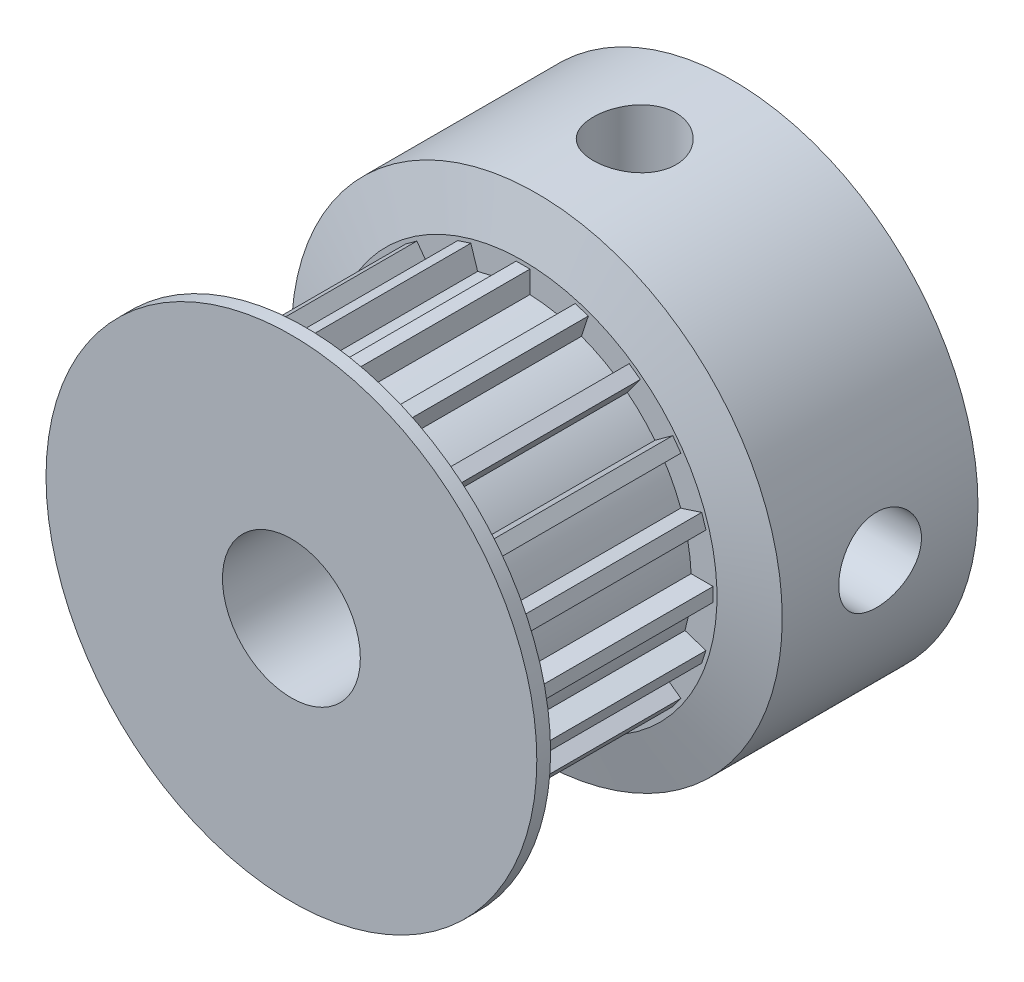
from build123d import *

# Parameters (mm, degrees)
CHAMFER1_SIZE       = 0.5
CHAMFER1_SIZE2      = 1.866025404
CHAMFER2_SIZE       = 0.5
CHAMFER2_SIZE2      = 1.866025404
BOSS_EXTRUDE1_DEPTH = 7.4
SKETCH6_R           = 1.5
CUT_EXTRUDE1_DEPTH  = 10
CIRPATTERN1_COUNT   = 2
CIRPATTERN1_ANGLE   = 270


with BuildPart() as part:
    # Sketch2 → Revolve1 (revolve)
    with BuildSketch(Plane(origin=(0, 0, 0), x_dir=(0, 0, -1), z_dir=(1, 0, 0))):
        Polygon((-16, 2.5), (0, 2.5), (0, 8.9), (-7.6, 8.9), (-7.6, 6.1), (-15, 6.1), (-15, 8.9), (-16, 8.9), align=None)
    revolve(axis=Axis((0, 0, 79.609460318), (0, 0, -1)))

    # Chamfer1
    chamfer1_edges = [part.edges().sort_by_distance(p)[0] for p in [
        (0, -8.9, 15),
    ]]
    chamfer1_side = [part.faces().sort_by_distance(p)[0] for p in [
        (0, -8.9, 15.5),
    ]]
    chamfer(chamfer1_edges, length=CHAMFER1_SIZE, length2=CHAMFER1_SIZE2, reference=chamfer1_side[0])

    # Chamfer2
    chamfer2_edges = [part.edges().sort_by_distance(p)[0] for p in [
        (0, -8.9, 7.6),
    ]]
    chamfer2_side = [part.faces().sort_by_distance(p)[0] for p in [
        (0, -8.9, 3.8),
    ]]
    chamfer(chamfer2_edges, length=CHAMFER2_SIZE, length2=CHAMFER2_SIZE2, reference=chamfer2_side[0])

    # Sketch4 → Boss-Extrude1 (add)
    with BuildSketch(Plane.XY.offset(7.6)):
        with BuildLine():
            Line((1.645655792, 5.873824735), (1.892869388, 6.634669948))
            Line((1.892869388, 6.634669948), (2.368397646, 6.48016145))
            Line((2.368397646, 6.48016145), (2.121184051, 5.719316237))
            ThreePointArc((2.121184051, 5.719316237), (1.885003666, 5.801444749), (1.645655792, 5.873824735))
        make_face()
        with BuildLine():
            Line((-0.25, 6.094874896), (-0.25, 6.894874896))
            Line((-0.25, 6.894874896), (0.25, 6.894874896))
            Line((0.25, 6.894874896), (0.25, 6.094874896))
            ThreePointArc((0.25, 6.094874896), (0, 6.1), (-0.25, 6.094874896))
        make_face()
        with BuildLine():
            Line((3.38022333, 5.077803683), (3.850451532, 5.725017278))
            Line((3.850451532, 5.725017278), (4.254960029, 5.431124652))
            Line((4.254960029, 5.431124652), (3.784731827, 4.783911057))
            ThreePointArc((3.784731827, 4.783911057), (3.585490039, 4.935003666), (3.38022333, 5.077803683))
        make_face()
        with BuildLine():
            Line((4.783911057, 3.784731827), (5.431124652, 4.254960029))
            Line((5.431124652, 4.254960029), (5.725017278, 3.850451532))
            Line((5.725017278, 3.850451532), (5.077803683, 3.38022333))
            ThreePointArc((5.077803683, 3.38022333), (4.935003666, 3.585490039), (4.783911057, 3.784731827))
        make_face()
        with BuildLine():
            Line((5.719316237, 2.121184051), (6.48016145, 2.368397646))
            Line((6.48016145, 2.368397646), (6.634669948, 1.892869388))
            Line((6.634669948, 1.892869388), (5.873824735, 1.645655792))
            ThreePointArc((5.873824735, 1.645655792), (5.801444749, 1.885003666), (5.719316237, 2.121184051))
        make_face()
        with BuildLine():
            Line((6.094874896, 0.25), (6.894874896, 0.25))
            Line((6.894874896, 0.25), (6.894874896, -0.25))
            Line((6.894874896, -0.25), (6.094874896, -0.25))
            ThreePointArc((6.094874896, -0.25), (6.1, 0), (6.094874896, 0.25))
        make_face()
        with BuildLine():
            Line((5.873824735, -1.645655792), (6.634669948, -1.892869388))
            Line((6.634669948, -1.892869388), (6.48016145, -2.368397646))
            Line((6.48016145, -2.368397646), (5.719316237, -2.121184051))
            ThreePointArc((5.719316237, -2.121184051), (5.801444749, -1.885003666), (5.873824735, -1.645655792))
        make_face()
        with BuildLine():
            Line((5.077803683, -3.38022333), (5.725017278, -3.850451532))
            Line((5.725017278, -3.850451532), (5.431124652, -4.254960029))
            Line((5.431124652, -4.254960029), (4.783911057, -3.784731827))
            ThreePointArc((4.783911057, -3.784731827), (4.935003666, -3.585490039), (5.077803683, -3.38022333))
        make_face()
        with BuildLine():
            Line((3.784731827, -4.783911057), (4.254960029, -5.431124652))
            Line((4.254960029, -5.431124652), (3.850451532, -5.725017278))
            Line((3.850451532, -5.725017278), (3.38022333, -5.077803683))
            ThreePointArc((3.38022333, -5.077803683), (3.585490039, -4.935003666), (3.784731827, -4.783911057))
        make_face()
        with BuildLine():
            Line((2.121184051, -5.719316237), (2.368397646, -6.48016145))
            Line((2.368397646, -6.48016145), (1.892869388, -6.634669948))
            Line((1.892869388, -6.634669948), (1.645655792, -5.873824735))
            ThreePointArc((1.645655792, -5.873824735), (1.885003666, -5.801444749), (2.121184051, -5.719316237))
        make_face()
        with BuildLine():
            Line((0.25, -6.094874896), (0.25, -6.894874896))
            Line((0.25, -6.894874896), (-0.25, -6.894874896))
            Line((-0.25, -6.894874896), (-0.25, -6.094874896))
            ThreePointArc((-0.25, -6.094874896), (0, -6.1), (0.25, -6.094874896))
        make_face()
        with BuildLine():
            Line((-1.645655792, -5.873824735), (-1.892869388, -6.634669948))
            Line((-1.892869388, -6.634669948), (-2.368397646, -6.48016145))
            Line((-2.368397646, -6.48016145), (-2.121184051, -5.719316237))
            ThreePointArc((-2.121184051, -5.719316237), (-1.885003666, -5.801444749), (-1.645655792, -5.873824735))
        make_face()
        with BuildLine():
            Line((-3.38022333, -5.077803683), (-3.850451532, -5.725017278))
            Line((-3.850451532, -5.725017278), (-4.254960029, -5.431124652))
            Line((-4.254960029, -5.431124652), (-3.784731827, -4.783911057))
            ThreePointArc((-3.784731827, -4.783911057), (-3.585490039, -4.935003666), (-3.38022333, -5.077803683))
        make_face()
        with BuildLine():
            Line((-4.783911057, -3.784731827), (-5.431124652, -4.254960029))
            Line((-5.431124652, -4.254960029), (-5.725017278, -3.850451532))
            Line((-5.725017278, -3.850451532), (-5.077803683, -3.38022333))
            ThreePointArc((-5.077803683, -3.38022333), (-4.935003666, -3.585490039), (-4.783911057, -3.784731827))
        make_face()
        with BuildLine():
            Line((-5.719316237, -2.121184051), (-6.48016145, -2.368397646))
            Line((-6.48016145, -2.368397646), (-6.634669948, -1.892869388))
            Line((-6.634669948, -1.892869388), (-5.873824735, -1.645655792))
            ThreePointArc((-5.873824735, -1.645655792), (-5.801444749, -1.885003666), (-5.719316237, -2.121184051))
        make_face()
        with BuildLine():
            Line((-6.094874896, -0.25), (-6.894874896, -0.25))
            Line((-6.894874896, -0.25), (-6.894874896, 0.25))
            Line((-6.894874896, 0.25), (-6.094874896, 0.25))
            ThreePointArc((-6.094874896, 0.25), (-6.1, 0), (-6.094874896, -0.25))
        make_face()
        with BuildLine():
            Line((-5.873824735, 1.645655792), (-6.634669948, 1.892869388))
            Line((-6.634669948, 1.892869388), (-6.48016145, 2.368397646))
            Line((-6.48016145, 2.368397646), (-5.719316237, 2.121184051))
            ThreePointArc((-5.719316237, 2.121184051), (-5.801444749, 1.885003666), (-5.873824735, 1.645655792))
        make_face()
        with BuildLine():
            Line((-5.077803683, 3.38022333), (-5.725017278, 3.850451532))
            Line((-5.725017278, 3.850451532), (-5.431124652, 4.254960029))
            Line((-5.431124652, 4.254960029), (-4.783911057, 3.784731827))
            ThreePointArc((-4.783911057, 3.784731827), (-4.935003666, 3.585490039), (-5.077803683, 3.38022333))
        make_face()
        with BuildLine():
            Line((-3.784731827, 4.783911057), (-4.254960029, 5.431124652))
            Line((-4.254960029, 5.431124652), (-3.850451532, 5.725017278))
            Line((-3.850451532, 5.725017278), (-3.38022333, 5.077803683))
            ThreePointArc((-3.38022333, 5.077803683), (-3.585490039, 4.935003666), (-3.784731827, 4.783911057))
        make_face()
        with BuildLine():
            Line((-2.121184051, 5.719316237), (-2.368397646, 6.48016145))
            Line((-2.368397646, 6.48016145), (-1.892869388, 6.634669948))
            Line((-1.892869388, 6.634669948), (-1.645655792, 5.873824735))
            ThreePointArc((-1.645655792, 5.873824735), (-1.885003666, 5.801444749), (-2.121184051, 5.719316237))
        make_face()
    extrude(amount=BOSS_EXTRUDE1_DEPTH)

    # Sketch6 → Cut-Extrude1 (cut)
    with BuildSketch(Plane(origin=(0, 8.9, 0), x_dir=(-1, 0, 0), z_dir=(0, 1, 0))):
        with Locations((0, 3.55)):
            Circle(SKETCH6_R)
    cut_extrude1 = extrude(amount=-CUT_EXTRUDE1_DEPTH, mode=Mode.SUBTRACT)

    # CirPattern1: Cut-Extrude1 ×2 about axis
    cirpattern1_axis = Axis((0, 0, 0), (0, 0, 1))
    for i in range(1, CIRPATTERN1_COUNT):
        add(cut_extrude1.rotate(cirpattern1_axis, i * CIRPATTERN1_ANGLE / (CIRPATTERN1_COUNT - 1)), mode=Mode.SUBTRACT)


solid = part.part
